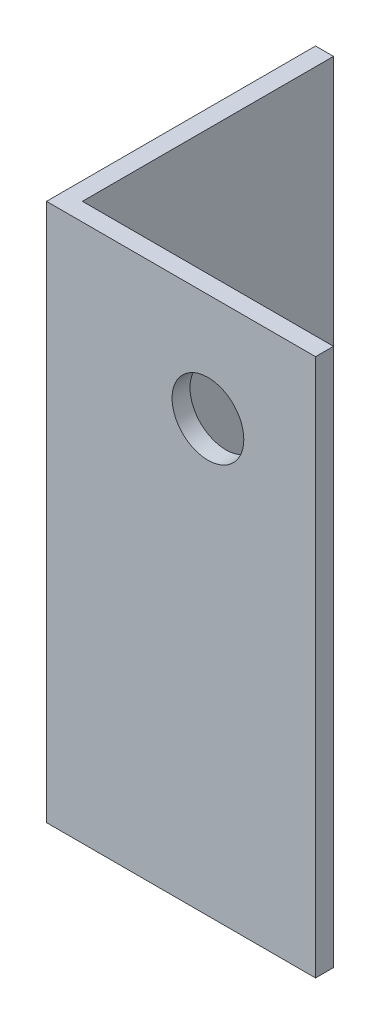
from build123d import *

# Parameters (mm, degrees)
EXTRUDE_1_DEPTH     = 150
SKETCH_2_R          = 10
CUT_EXTRUDE_1_DEPTH = 76


with BuildPart() as part:
    # Эскиз1 → Вытянуть-Тонкостенный1 (new body)
    with BuildSketch(Plane(origin=(0, 0, 0), x_dir=(1, 0, 0), z_dir=(0, 1, 0))):
        Polygon((0, 75), (0, 0), (75, 0), (75, 5), (5, 5), (5, 75), align=None)
    extrude(amount=EXTRUDE_1_DEPTH)

    # Эскиз2 → Вырез-Вытянуть1 (cut, through all)
    with BuildSketch(Plane.XY):
        with Locations((45, 120)):
            Circle(SKETCH_2_R)
    extrude(amount=-CUT_EXTRUDE_1_DEPTH, mode=Mode.SUBTRACT)


solid = part.part
